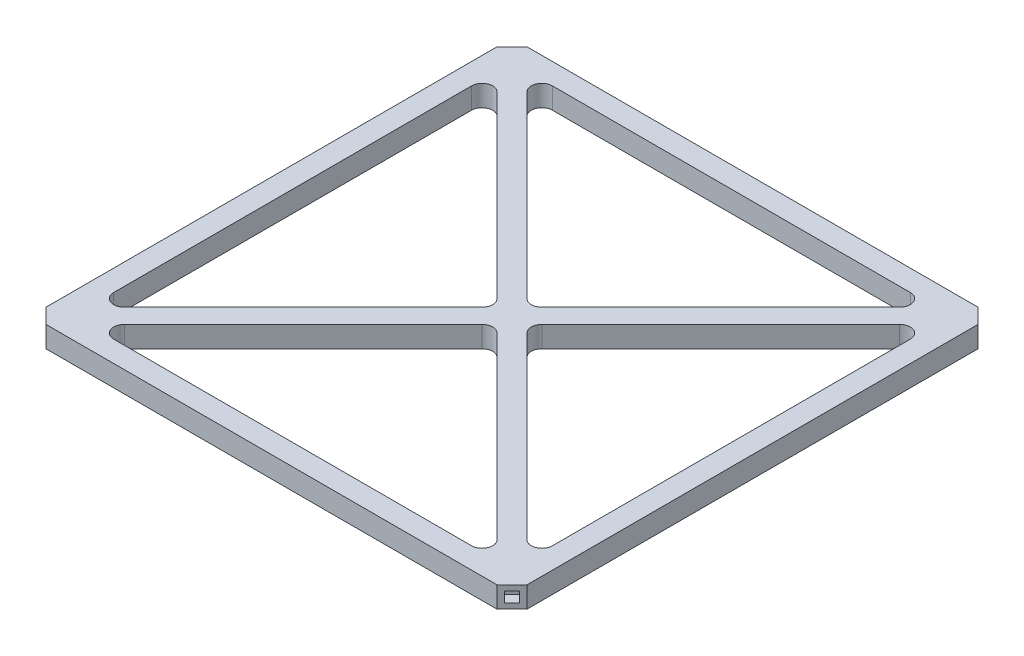
from build123d import *

# Parameters (mm, degrees)
BOSS_EXTRUDE1_DEPTH = 20
SKETCH3_W           = 10
SKETCH3_H           = 10
CUT_EXTRUDE1_DEPTH  = 10
CIRPATTERN1_COUNT   = 4


with BuildPart() as part:
    # Sketch1 → Boss-Extrude1 (new body)
    with BuildSketch(Plane(origin=(0, 0, 0), x_dir=(1, 0, 0), z_dir=(0, 1, 0))):
        Polygon((213.546247918, 227.688383542), (227.688383542, 213.546247918), (227.688383542, -213.546247918), (213.546247918, -227.688383542), (-213.546247918, -227.688383542), (-227.688383542, -213.546247918), (-227.688383542, 213.546247918), (-213.546247918, 227.688383542), align=None)
        with BuildLine():
            Line((21.213203436, 7.071067812), (190.61731573, 176.475180106))
            ThreePointArc((190.61731573, 176.475180106), (201.515217866, 178.64290762), (207.688383542, 169.404112295))
            Line((207.688383542, 169.404112295), (207.688383542, -169.404112295))
            ThreePointArc((207.688383542, -169.404112295), (201.515217866, -178.64290762), (190.61731573, -176.475180106))
            Line((190.61731573, -176.475180106), (21.213203436, -7.071067812))
            ThreePointArc((21.213203436, -7.071067812), (18.284271247, 0), (21.213203436, 7.071067812))
        make_face(mode=Mode.SUBTRACT)
        with BuildLine():
            Line((7.071067812, -21.213203436), (176.475180106, -190.61731573))
            ThreePointArc((176.475180106, -190.61731573), (178.64290762, -201.515217866), (169.404112295, -207.688383542))
            Line((169.404112295, -207.688383542), (-169.404112295, -207.688383542))
            ThreePointArc((-169.404112295, -207.688383542), (-178.64290762, -201.515217866), (-176.475180106, -190.61731573))
            Line((-176.475180106, -190.61731573), (-7.071067812, -21.213203436))
            ThreePointArc((-7.071067812, -21.213203436), (0, -18.284271247), (7.071067812, -21.213203436))
        make_face(mode=Mode.SUBTRACT)
        with BuildLine():
            Line((-21.213203436, -7.071067812), (-190.61731573, -176.475180106))
            ThreePointArc((-190.61731573, -176.475180106), (-201.515217866, -178.64290762), (-207.688383542, -169.404112295))
            Line((-207.688383542, -169.404112295), (-207.688383542, 169.404112295))
            ThreePointArc((-207.688383542, 169.404112295), (-201.515217866, 178.64290762), (-190.61731573, 176.475180106))
            Line((-190.61731573, 176.475180106), (-21.213203436, 7.071067812))
            ThreePointArc((-21.213203436, 7.071067812), (-18.284271247, 0), (-21.213203436, -7.071067812))
        make_face(mode=Mode.SUBTRACT)
        with BuildLine():
            Line((-7.071067812, 21.213203436), (-176.475180106, 190.61731573))
            ThreePointArc((-176.475180106, 190.61731573), (-178.64290762, 201.515217866), (-169.404112295, 207.688383542))
            Line((-169.404112295, 207.688383542), (169.404112295, 207.688383542))
            ThreePointArc((169.404112295, 207.688383542), (178.64290762, 201.515217866), (176.475180106, 190.61731573))
            Line((176.475180106, 190.61731573), (7.071067812, 21.213203436))
            ThreePointArc((7.071067812, 21.213203436), (0, 18.284271247), (-7.071067812, 21.213203436))
        make_face(mode=Mode.SUBTRACT)
    extrude(amount=BOSS_EXTRUDE1_DEPTH)

    # Sketch3 → Cut-Extrude1 (cut)
    with BuildSketch(Plane(origin=(220.61731573, 0, -220.61731573), x_dir=(-0.7071067811865545, 0, -0.7071067811865407), z_dir=(0.7071067811865407, 0, -0.7071067811865545))):
        with Locations((0, 10)):
            Rectangle(SKETCH3_W, SKETCH3_H)
    cut_extrude1 = extrude(amount=-CUT_EXTRUDE1_DEPTH, mode=Mode.SUBTRACT)

    # CirPattern1: Cut-Extrude1 ×4 about axis
    cirpattern1_axis = Axis((0, -1, 0), (0, 1, 0))
    for i in range(1, CIRPATTERN1_COUNT):
        add(cut_extrude1.rotate(cirpattern1_axis, i * 360 / CIRPATTERN1_COUNT), mode=Mode.SUBTRACT)


solid = part.part
